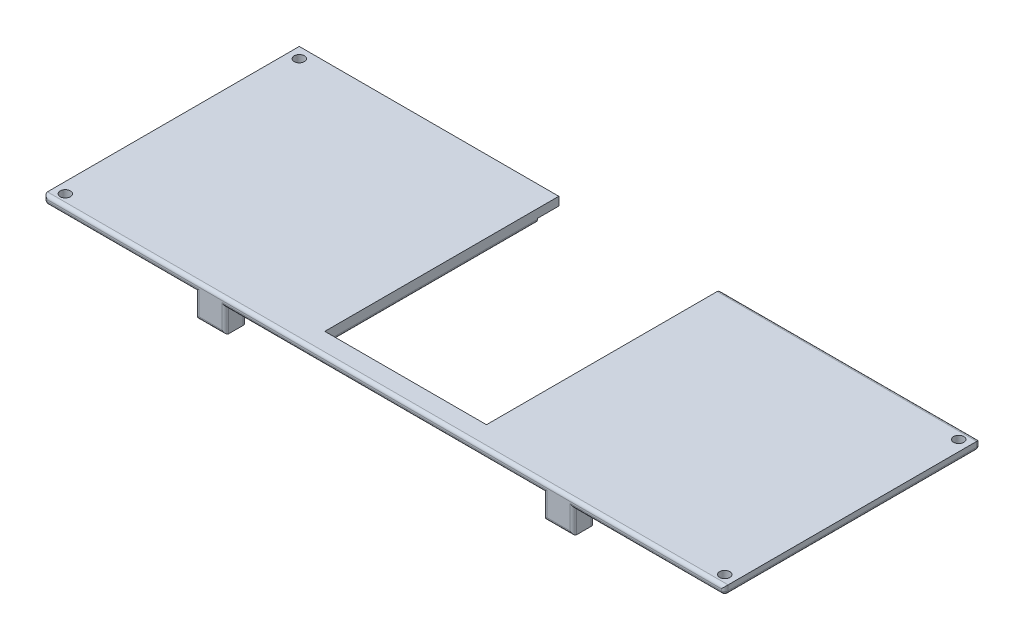
from build123d import *

# Parameters (mm, degrees)
SKETCH1_R             = 0.6
BOSS_EXTRUDE1_DEPTH   = 1
SKETCH1_W             = 37.4
SKETCH1_H             = 2.5
BOSS_EXTRUDE1_2_DEPTH = 1
BOSS_EXTRUDE1_3_DEPTH = 1
BOSS_EXTRUDE1_4_DEPTH = 1
SKETCH1_W_2           = 9.2
BOSS_EXTRUDE1_5_DEPTH = 1
BOSS_EXTRUDE2_DEPTH   = 1.5
SKETCH4_W             = 3.5
SKETCH4_H             = 2.5
BOSS_EXTRUDE3_DEPTH   = 3.8
FILLET1_R             = 0.4


with BuildPart() as part:
    # Sketch1 → Boss-Extrude1 (new body)
    with BuildSketch(Plane(origin=(0, 0, 0), x_dir=(1, 0, 0), z_dir=(0, 1, 0))):
        Polygon((-22.2, 30), (-25.229966902, 30), (-40, 30), (-40, 0), (-25.229966902, 0), (-22.2, 0), (-22.2, 2.5), (-37.5, 2.5), (-37.5, 27.5), (-22.2, 27.5), align=None)
        with Locations((-38.75, 1.25)):
            Circle(SKETCH1_R, mode=Mode.SUBTRACT)
        with Locations((-38.75, 28.75)):
            Circle(SKETCH1_R, mode=Mode.SUBTRACT)
    extrude(amount=-BOSS_EXTRUDE1_DEPTH)



with BuildPart() as body_2:
    # Sketch1 → Boss-Extrude1 2 (new body)
    with BuildSketch(Plane(origin=(0, 0, 0), x_dir=(1, 0, 0), z_dir=(0, 1, 0))):
        with Locations((0, 1.25)):
            Rectangle(SKETCH1_W, SKETCH1_H)
    extrude(amount=-BOSS_EXTRUDE1_2_DEPTH)


with BuildPart() as body_3:
    # Sketch1 → Boss-Extrude1 3 (new body)
    with BuildSketch(Plane(origin=(0, 0, 0), x_dir=(1, 0, 0), z_dir=(0, 1, 0))):
        Polygon((12, 30), (10, 30), (9.5, 30), (9.5, 27.5), (18.7, 27.5), (18.7, 30), align=None)
    extrude(amount=-BOSS_EXTRUDE1_3_DEPTH)


with BuildPart() as body_4:
    # Sketch1 → Boss-Extrude1 4 (new body)
    with BuildSketch(Plane(origin=(0, 0, 0), x_dir=(1, 0, 0), z_dir=(0, 1, 0))):
        Polygon((25.229966902, 30), (22.2, 30), (22.2, 27.5), (37.5, 27.5), (37.5, 2.5), (22.2, 2.5), (22.2, 0), (25.229966902, 0), (40, 0), (40, 30), align=None)
        with Locations((38.75, 1.25)):
            Circle(SKETCH1_R, mode=Mode.SUBTRACT)
        with Locations((38.75, 28.75)):
            Circle(SKETCH1_R, mode=Mode.SUBTRACT)
    extrude(amount=-BOSS_EXTRUDE1_4_DEPTH)


with BuildPart() as body_5:
    # Sketch1 → Boss-Extrude1 5 (new body)
    with BuildSketch(Plane(origin=(0, 0, 0), x_dir=(1, 0, 0), z_dir=(0, 1, 0))):
        with Locations((-14.1, 28.75)):
            Rectangle(SKETCH1_W_2, SKETCH1_H)
    extrude(amount=-BOSS_EXTRUDE1_5_DEPTH)


with BuildPart() as part_1:
    add(part.part)

    add(body_2.part)  # Boss-Extrude2 merges body 2

    add(body_3.part)  # Boss-Extrude2 merges body 3

    add(body_4.part)  # Boss-Extrude2 merges body 4

    add(body_5.part)  # Boss-Extrude2 merges body 5
    # Sketch3 → Boss-Extrude2 (add)
    with BuildSketch(Plane(origin=(0, 0, 0), x_dir=(1, 0, 0), z_dir=(0, 1, 0))):
        Polygon((-22.2, 27.5), (-37.5, 27.5), (-37.5, 2.5), (-22.2, 2.5), (-22.2, 0), (-18.7, 0), (-18.7, 2.5), (-9.5, 2.5), (-9.5, 27.5), (-18.7, 27.5), (-18.7, 30), (-22.2, 30), align=None)
        Polygon((9.5, 27.5), (18.7, 27.5), (18.7, 30), (22.2, 30), (22.2, 27.5), (37.5, 27.5), (37.5, 2.5), (22.2, 2.5), (22.2, 0), (18.7, 0), (18.7, 2.5), (9.5, 2.5), align=None)
    extrude(amount=-BOSS_EXTRUDE2_DEPTH)

    # Sketch4 → Boss-Extrude3 (add)
    with BuildSketch(Plane(origin=(0, 0, 0), x_dir=(1, 0, 0), z_dir=(0, 1, 0))):
        with Locations((-20.45, 28.75)):
            Rectangle(SKETCH4_W, SKETCH4_H)
        with Locations((20.45, 28.75)):
            Rectangle(SKETCH4_W, SKETCH4_H)
        with Locations((-20.45, 1.25)):
            Rectangle(SKETCH4_W, SKETCH4_H)
        with Locations((20.45, 1.25)):
            Rectangle(SKETCH4_W, SKETCH4_H)
    extrude(amount=-BOSS_EXTRUDE3_DEPTH)

    # Fillet1
    fillet1_edges = [part_1.edges().sort_by_distance(p)[0] for p in [
        (-22.2, -2.65, -27.5),
        (-18.7, -2.65, -27.5),
        (-18.7, -2.4, -30),
        (-22.2, -2.4, -30),
        (14.1, -1, -30),
        (18.7, -2.4, -30),
        (20.45, -3.8, -30),
        (22.2, -2.4, -30),
        (31.1, -1, -30),
        (40, -0.5, -30),
        (24.75, 0, -30),
        (9.5, -0.5, -30),
        (-18.7, -2.4, 0),
        (-20.45, -3.8, 0),
        (-22.2, -2.4, 0),
        (-31.1, -1, 0),
        (-40, -0.5, 0),
        (0, 0, 0),
        (40, -0.5, 0),
        (31.1, -1, 0),
        (22.2, -2.4, 0),
        (20.45, -3.8, 0),
        (18.7, -2.4, 0),
        (0, -1, 0),
        (-40, -1, -15),
        (0, -1, -2.5),
        (9.5, -1.5, -15),
        (-9.5, -1.5, -15),
        (40, -1, -15),
        (37.5, -1.5, -15),
        (-37.5, -1.5, -15),
        (-18.7, -2.65, -2.5),
        (-22.2, -2.65, -2.5),
        (18.7, -2.65, -2.5),
        (22.2, -2.65, -2.5),
        (22.2, -2.65, -27.5),
        (18.7, -2.65, -27.5),
    ]]
    fillet(fillet1_edges, radius=FILLET1_R)


solid = part_1.part
